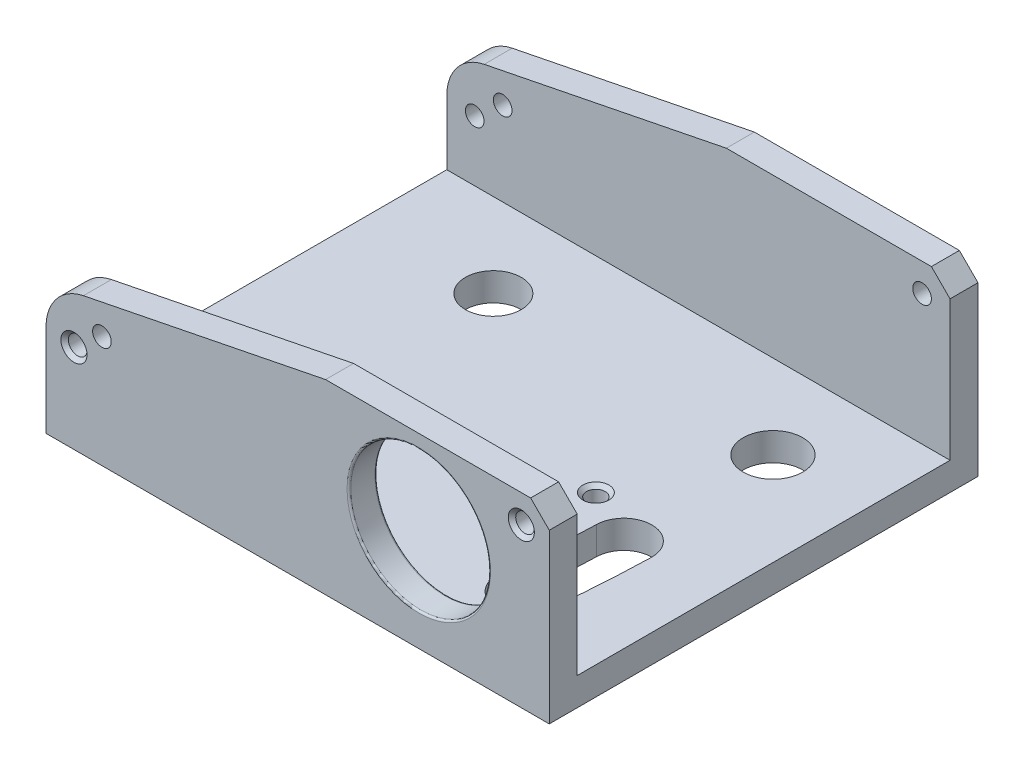
from build123d import *

# Parameters (mm, degrees)
SKETCH1_W      = 27
SKETCH1_H      = 23
SKETCH1_R      = 1.6
SKETCH1_R_2    = 1.5
SKETCH1_R_3    = 0.5
EXTRUDE1_DEPTH = 1.5
SKETCH2_R      = 0.5
SKETCH2_R_2    = 3.75
EXTRUDE2_DEPTH = 1.5
SKETCH3_R      = 0.5
EXTRUDE3_DEPTH = 1.5
FILLET1_R      = 0.1
CHAMFER1_SIZE  = 0.2
FILLET2_R      = 2.5


with BuildPart() as part:
    # Sketch1 → Extrude1 (new body)
    with BuildSketch(Plane(origin=(0, 0, 0), x_dir=(1, 0, 0), z_dir=(0, 1, 0))):
        with Locations((-8.5, -5.5)):
            Rectangle(SKETCH1_W, SKETCH1_H)
        with Locations(Location((0, 0, 0), (0, 0, 270))):  # turned: the seam where the file's is
            Circle(SKETCH1_R, mode=Mode.SUBTRACT)
        with Locations(Location((-15, 0, 0), (0, 0, 270))):  # turned: the seam where the file's is
            Circle(SKETCH1_R_2, mode=Mode.SUBTRACT)
        with Locations(Location((-3, -6.5, 0), (0, 0, 270))):  # turned: the seam where the file's is
            Circle(SKETCH1_R_3, mode=Mode.SUBTRACT)
        with BuildLine():
            ThreePointArc((-1.814657257, -12.850061187), (-1.613249333, -10.406431255), (-1.49938813, -7.957160339))
            ThreePointArc((-1.49938813, -7.957160339), (0.042839661, -6.50061187), (1.49938813, -8.042839661))
            ThreePointArc((1.49938813, -8.042839661), (1.380542383, -10.599333203), (1.170317351, -13.149938813))
            ThreePointArc((1.170317351, -13.149938813), (-0.472108766, -14.492487304), (-1.814657257, -12.850061187))
        make_face(mode=Mode.SUBTRACT)
    extrude(amount=EXTRUDE1_DEPTH)

    # Sketch2 → Extrude2 (add)
    with BuildSketch(Plane.XY.offset(17)):
        Polygon((-22, 1.5), (5, 1.5), (5, 9), (4, 10), (-7, 10), (-22, 7), align=None)
        with Locations((3.5, 8.5)):
            Circle(SKETCH2_R, mode=Mode.SUBTRACT)
        with Locations((-2, 5.5)):
            Circle(SKETCH2_R_2, mode=Mode.SUBTRACT)
        with Locations((-20.5, 4.75)):
            Circle(SKETCH2_R, mode=Mode.SUBTRACT)
        with Locations((-19, 6)):
            Circle(SKETCH2_R, mode=Mode.SUBTRACT)
    extrude(amount=-EXTRUDE2_DEPTH)

    # Sketch3 → Extrude3 (add)
    with BuildSketch(Plane(origin=(0, 0, -6), x_dir=(-1, 0, 0), z_dir=(0, 0, -1))):
        Polygon((-5, 1.5), (22, 1.5), (22, 7), (7, 10), (-4, 10), (-5, 9), align=None)
        with Locations(Location((-3.5, 8.5, 0), (0, 0, 180))):  # turned: the seam where the file's is
            Circle(SKETCH3_R, mode=Mode.SUBTRACT)
        with Locations(Location((20.5, 4.75, 0), (0, 0, 180))):  # turned: the seam where the file's is
            Circle(SKETCH3_R, mode=Mode.SUBTRACT)
        with Locations(Location((19, 6, 0), (0, 0, 180))):  # turned: the seam where the file's is
            Circle(SKETCH3_R, mode=Mode.SUBTRACT)
    extrude(amount=-EXTRUDE3_DEPTH)

    # Fillet1
    fillet1_edges = [part.edges().sort_by_distance(p)[0] for p in [
        (-5.75, 5.5, 15.5),
        (-5.75, 5.5, 17),
    ]]
    fillet(fillet1_edges, radius=FILLET1_R)

    # Chamfer1
    chamfer1_edges = [part.edges().sort_by_distance(p)[0] for p in [
        (-3, 0, 6),
        (-3, 1.5, 6),
        (3, 8.5, 17),
        (-21, 4.75, 17),
        (3, 8.5, -6),
        (-21, 4.75, -6),
    ]]
    chamfer(chamfer1_edges, length=CHAMFER1_SIZE)

    # Fillet2
    fillet2_edges = [part.edges().sort_by_distance(p)[0] for p in [
        (-22, 7, 16.25),
        (-22, 7, -5.25),
    ]]
    fillet(fillet2_edges, radius=FILLET2_R)


solid = part.part
